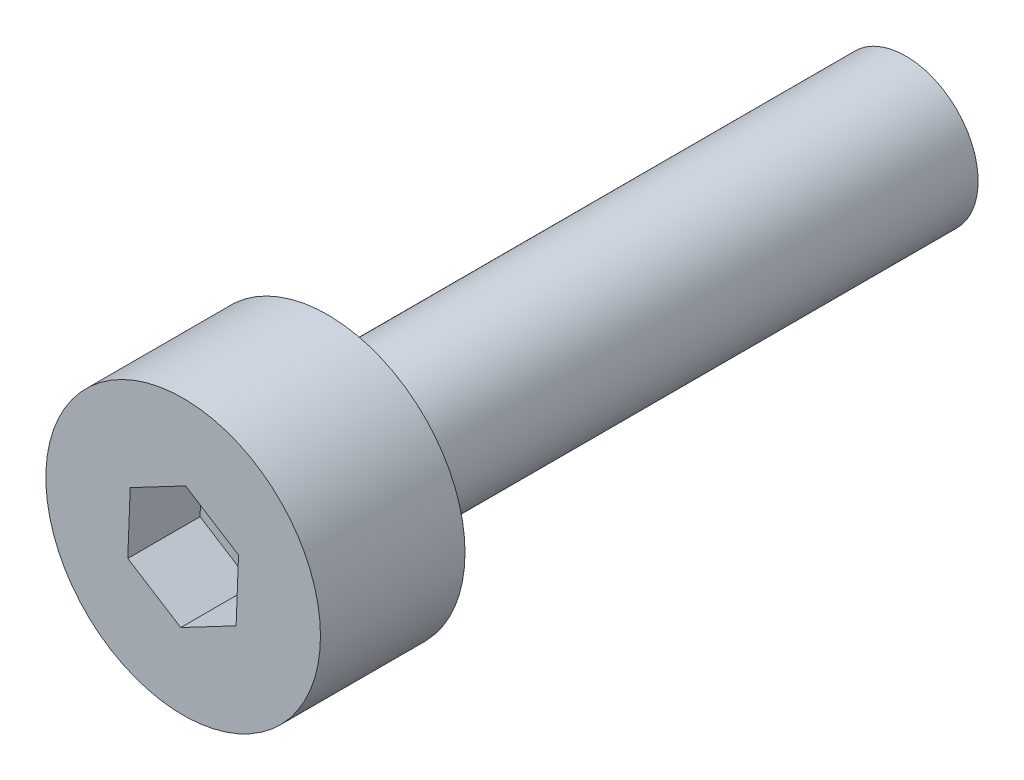
from build123d import *

# Parameters (mm, degrees)
SKETCH_1_R          = 1.9
EXTRUDE_1_DEPTH     = 2
SKETCH_2_R          = 1
EXTRUDE_2_DEPTH     = 8
CUT_EXTRUDE_1_DEPTH = 1


with BuildPart() as part:
    # 草图1 → 凸台-拉伸1 (new body)
    with BuildSketch(Plane.XY):
        Circle(SKETCH_1_R)
    extrude(amount=EXTRUDE_1_DEPTH)

    # 草图2 → 凸台-拉伸2 (add)
    with BuildSketch(Plane(origin=(0, 0, 0), x_dir=(-1, 0, 0), z_dir=(0, 0, -1))):
        Circle(SKETCH_2_R)
    extrude(amount=EXTRUDE_2_DEPTH)

    # 草图3 → 切除-拉伸1 (cut)
    with BuildSketch(Plane.XY.offset(2)):
        Polygon((-0.766222709, -0.403612141), (-0.033572987, -0.865374401), (0.732649722, -0.461762261), (0.766222709, 0.403612141), (0.033572987, 0.865374401), (-0.732649722, 0.461762261), align=None)
    extrude(amount=-CUT_EXTRUDE_1_DEPTH, mode=Mode.SUBTRACT)


solid = part.part
